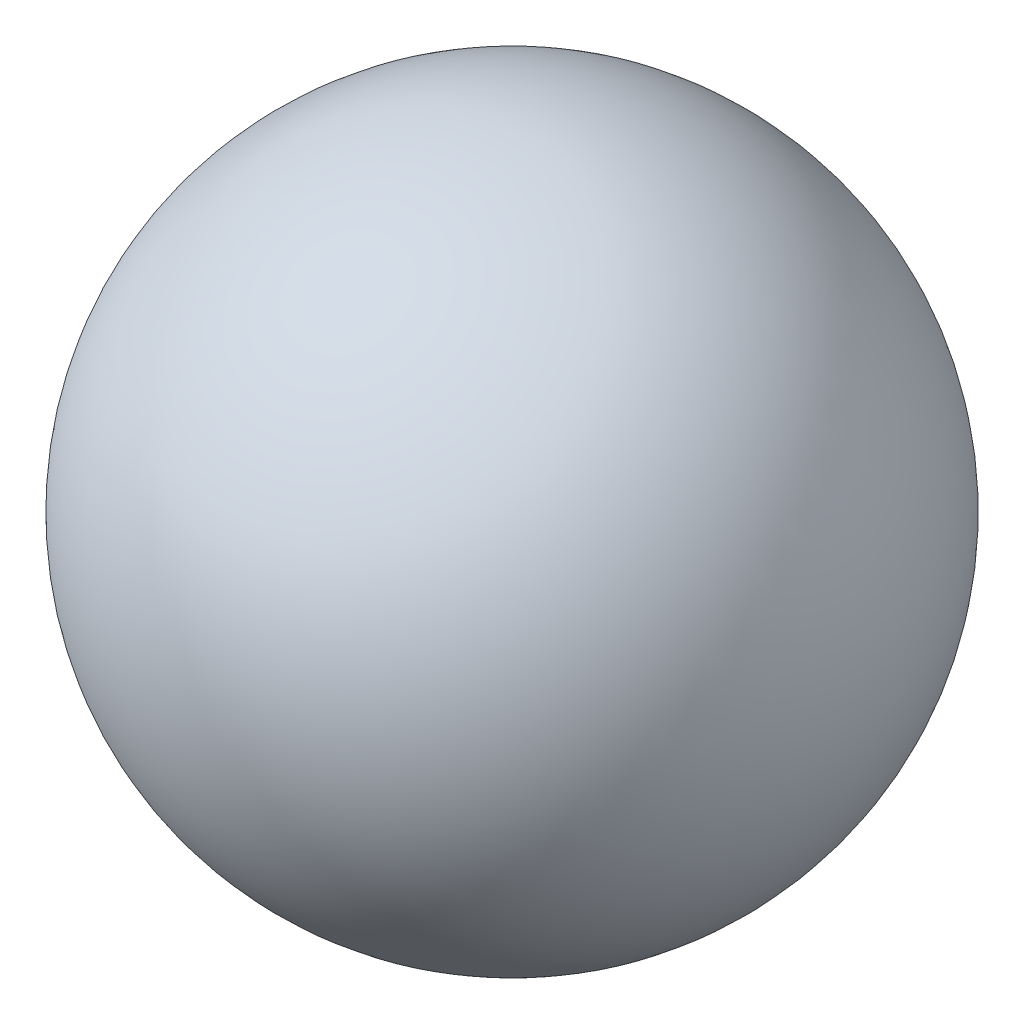
from build123d import *


with BuildPart() as part:
    # 草图1 → 旋转1 (revolve)
    with BuildSketch(Plane.XY):
        with BuildLine():
            Line((0, -20), (0, 20))
            ThreePointArc((0, 20), (-20, 0), (0, -20))
        make_face()
    revolve(axis=Axis((0, 29.60705824, 0), (0, -1, 0)))


solid = part.part
